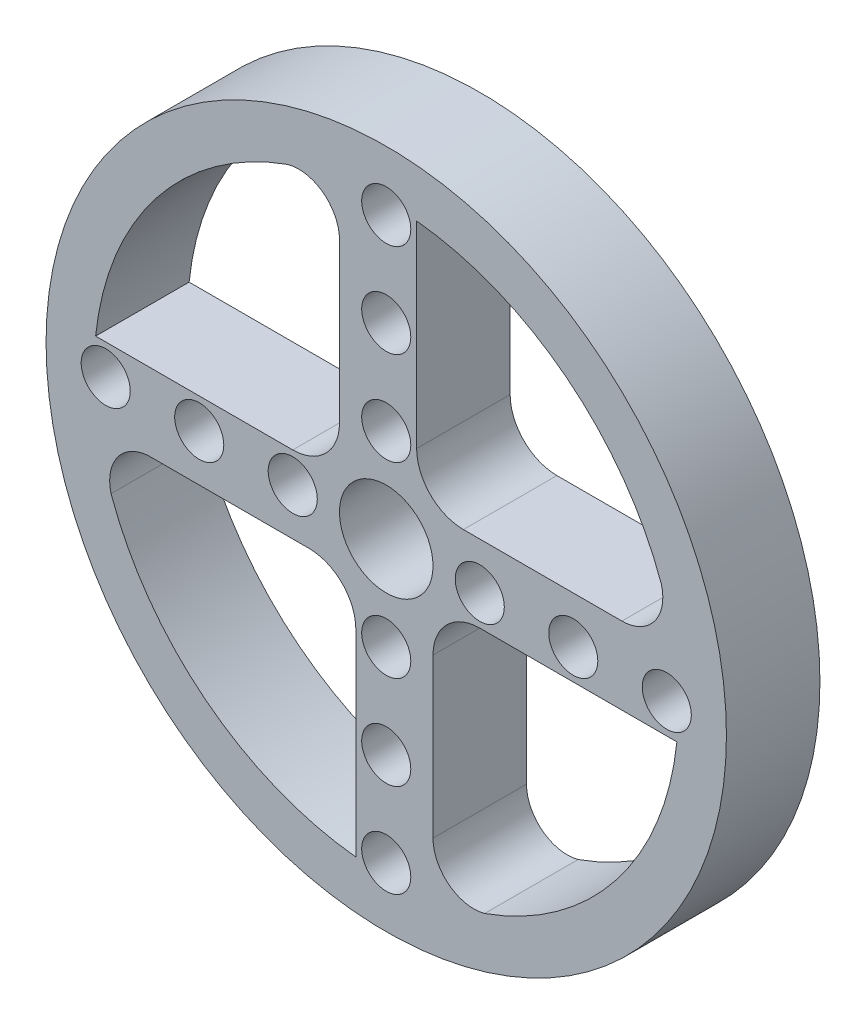
from build123d import *

# Parameters (mm, degrees)
CROQUIS1_R              = 29.105
CROQUIS1_R_2            = 4
CROQUIS1_R_3            = 2.1
SALIENTE_EXTRUIR1_DEPTH = 8


with BuildPart() as part:
    # Croquis1 → Saliente-Extruir1 (new body)
    with BuildSketch(Plane.XY):
        Circle(CROQUIS1_R)
        Circle(CROQUIS1_R_2, mode=Mode.SUBTRACT)
        with BuildLine():
            ThreePointArc((6.6, 4), (3.771572875, 5.171572875), (2.6, 8))
            Line((2.6, 8), (2.6, 24.864432429))
            ThreePointArc((2.6, 24.864432429), (15.442895729, 19.66003488), (23.541098272, 8.415265423))
            ThreePointArc((23.541098272, 8.415265423), (22.942587119, 5.373198291), (20.162890285, 4))
            Line((20.162890285, 4), (6.6, 4))
        make_face(mode=Mode.SUBTRACT)
        with Locations((0, 24)):
            Circle(CROQUIS1_R_3, mode=Mode.SUBTRACT)
        with BuildLine():
            ThreePointArc((-8.415265423, 23.541098272), (-5.373198291, 22.942587119), (-4, 20.162890285))
            Line((-4, 20.162890285), (-4, 6.6))
            ThreePointArc((-4, 6.6), (-5.171572875, 3.771572875), (-8, 2.6))
            Line((-8, 2.6), (-24.864432429, 2.6))
            ThreePointArc((-24.864432429, 2.6), (-19.66003488, 15.442895729), (-8.415265423, 23.541098272))
        make_face(mode=Mode.SUBTRACT)
        with Locations((-24, 0)):
            Circle(CROQUIS1_R_3, mode=Mode.SUBTRACT)
        with BuildLine():
            ThreePointArc((-23.541098272, -8.415265423), (-22.942587119, -5.373198291), (-20.162890285, -4))
            Line((-20.162890285, -4), (-6.6, -4))
            ThreePointArc((-6.6, -4), (-3.771572875, -5.171572875), (-2.6, -8))
            Line((-2.6, -8), (-2.6, -24.864432429))
            ThreePointArc((-2.6, -24.864432429), (-15.442895729, -19.66003488), (-23.541098272, -8.415265423))
        make_face(mode=Mode.SUBTRACT)
        with Locations((0, -24)):
            Circle(CROQUIS1_R_3, mode=Mode.SUBTRACT)
        with BuildLine():
            ThreePointArc((8.415265423, -23.541098272), (5.373198291, -22.942587119), (4, -20.162890285))
            Line((4, -20.162890285), (4, -6.6))
            ThreePointArc((4, -6.6), (5.171572875, -3.771572875), (8, -2.6))
            Line((8, -2.6), (24.864432429, -2.6))
            ThreePointArc((24.864432429, -2.6), (19.66003488, -15.442895729), (8.415265423, -23.541098272))
        make_face(mode=Mode.SUBTRACT)
        with Locations((24, 0)):
            Circle(CROQUIS1_R_3, mode=Mode.SUBTRACT)
        with Locations((0, -8)):
            Circle(CROQUIS1_R_3, mode=Mode.SUBTRACT)
        with Locations((0, -16)):
            Circle(CROQUIS1_R_3, mode=Mode.SUBTRACT)
        with Locations((-8, 0)):
            Circle(CROQUIS1_R_3, mode=Mode.SUBTRACT)
        with Locations((-16, 0)):
            Circle(CROQUIS1_R_3, mode=Mode.SUBTRACT)
        with Locations((0, 8)):
            Circle(CROQUIS1_R_3, mode=Mode.SUBTRACT)
        with Locations((0, 16)):
            Circle(CROQUIS1_R_3, mode=Mode.SUBTRACT)
        with Locations((16, 0)):
            Circle(CROQUIS1_R_3, mode=Mode.SUBTRACT)
        with Locations((8, 0)):
            Circle(CROQUIS1_R_3, mode=Mode.SUBTRACT)
    extrude(amount=SALIENTE_EXTRUIR1_DEPTH)


solid = part.part
